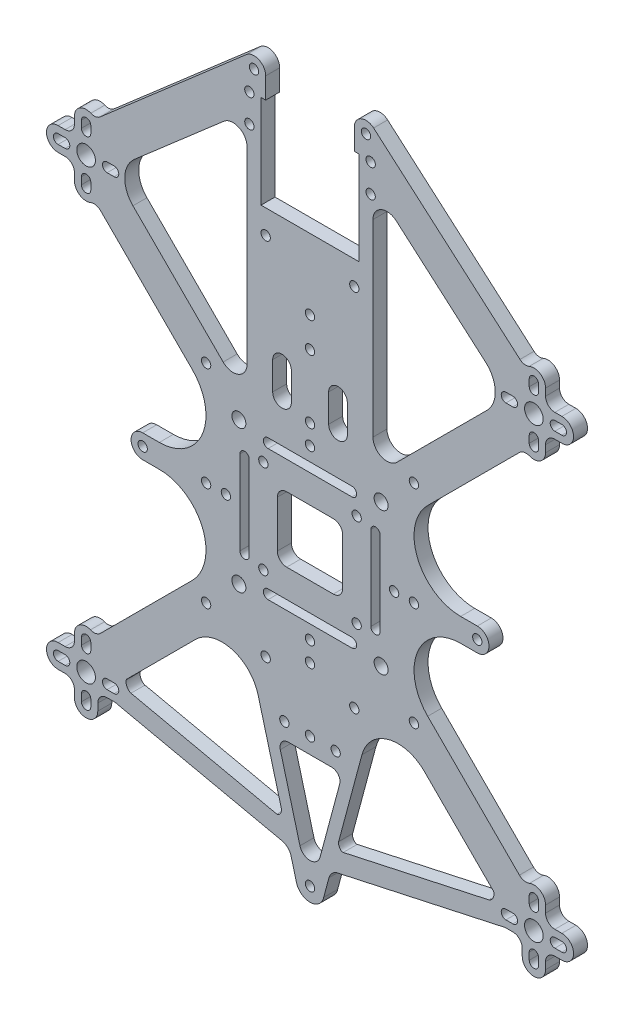
from build123d import *

# Parameters (mm, degrees)
MODEL_R         = 1
MODEL_R_2       = 2
MODEL_R_3       = 1.5
EXTRUDE_1_DEPTH = 3


with BuildPart() as part:
    # Model → 凸台-拉伸1 (new body)
    with BuildSketch(Plane.XY):
        with BuildLine():
            Line((38.972168987, 86.626017935), (42.537402622, 86.626017935))
            ThreePointArc((42.537402622, 86.626017935), (51.776388707, 92.799644178), (49.607765401, 103.69779071))
            Line((49.607765401, 103.69779071), (29.942441108, 123.35919406))
            ThreePointArc((29.942441108, 123.35919406), (28.926588779, 123.904793752), (27.778364563, 123.798887513))
            ThreePointArc((27.778364563, 123.798887513), (25.443319321, 124.043555525), (24.340859577, 126.116447523))
            Line((24.340859577, 126.116447523), (24.340859577, 127.616447523))
            ThreePointArc((24.340859577, 127.616447523), (23.755073139, 129.030661085), (22.340859577, 129.616447523))
            Line((22.340859577, 129.616447523), (20.840859577, 129.616447523))
            ThreePointArc((20.840859577, 129.616447523), (18.340859577, 132.116447523), (20.840859577, 134.616447523))
            Line((20.840859577, 134.616447523), (22.340859577, 134.616447523))
            ThreePointArc((22.340859577, 134.616447523), (23.755073139, 135.20223396), (24.340859577, 136.616447523))
            Line((24.340859577, 136.616447523), (24.340859577, 138.116447523))
            ThreePointArc((24.340859577, 138.116447523), (25.472512866, 140.208725535), (27.8429614, 140.406816911))
            ThreePointArc((27.8429614, 140.406816911), (28.877503873, 140.271078773), (29.824404932, 140.709349642))
            Line((29.824404932, 140.709349642), (61.200947719, 167.97768131))
            ThreePointArc((61.200947719, 167.97768131), (63.877734776, 168.365540898), (65.340859577, 166.090702481))
            Line((65.340859577, 166.090702481), (65.340859577, 161.590702481))
            Line((65.340859577, 161.590702481), (64.340859577, 161.590702481))
            Line((64.340859577, 161.590702481), (64.340859577, 141.590702481))
            Line((64.340859577, 141.590702481), (74.840859577, 141.590702481))
            Line((74.840859577, 141.590702481), (85.340859577, 141.590702481))
            Line((85.340859577, 141.590702481), (85.340859577, 161.590702481))
            Line((85.340859577, 161.590702481), (84.340859577, 161.590702481))
            Line((84.340859577, 161.590702481), (84.340859577, 166.090702481))
            ThreePointArc((84.340859577, 166.090702481), (85.803984377, 168.365540898), (88.480771434, 167.97768131))
            Line((88.480771434, 167.97768131), (119.857314221, 140.709349642))
            ThreePointArc((119.857314221, 140.709349642), (120.80421528, 140.271078773), (121.838757753, 140.406816911))
            ThreePointArc((121.838757753, 140.406816911), (124.209206287, 140.208725535), (125.340859577, 138.116447523))
            Line((125.340859577, 138.116447523), (125.340859577, 136.616447523))
            ThreePointArc((125.340859577, 136.616447523), (125.926646014, 135.20223396), (127.340859577, 134.616447523))
            Line((127.340859577, 134.616447523), (128.840859577, 134.616447523))
            ThreePointArc((128.840859577, 134.616447523), (131.340859577, 132.116447523), (128.840859577, 129.616447523))
            Line((128.840859577, 129.616447523), (127.340859576, 129.616447523))
            ThreePointArc((127.340859576, 129.616447523), (125.926646014, 129.030661085), (125.340859577, 127.616447523))
            Line((125.340859577, 127.616447523), (125.340859577, 126.116447523))
            ThreePointArc((125.340859577, 126.116447523), (124.238399832, 124.043555525), (121.90335459, 123.798887513))
            ThreePointArc((121.90335459, 123.798887513), (120.755130374, 123.904793752), (119.739278045, 123.35919406))
            Line((119.739278045, 123.35919406), (100.073953752, 103.69779071))
            ThreePointArc((100.073953752, 103.69779071), (97.905330446, 92.799644178), (107.144316531, 86.626017935))
            Line((107.144316531, 86.626017935), (110.709550166, 86.626017935))
            ThreePointArc((110.709550166, 86.626017935), (113.209550166, 84.126017935), (110.709550166, 81.626017935))
            Line((110.709550166, 81.626017935), (107.144316531, 81.626017935))
            ThreePointArc((107.144316531, 81.626017935), (97.905330446, 75.452391692), (100.073953752, 64.554245161))
            Line((100.073953752, 64.554245161), (119.739278045, 44.892841811))
            ThreePointArc((119.739278045, 44.892841811), (120.755130374, 44.347242119), (121.90335459, 44.453148358))
            ThreePointArc((121.90335459, 44.453148358), (124.238399832, 44.208480346), (125.340859577, 42.135588348))
            Line((125.340859577, 42.135588348), (125.340859577, 40.635588348))
            ThreePointArc((125.340859577, 40.635588348), (125.926646014, 39.221374786), (127.340859576, 38.635588348))
            Line((127.340859576, 38.635588348), (128.840859577, 38.635588348))
            ThreePointArc((128.840859577, 38.635588348), (131.340859577, 36.135588348), (128.840859577, 33.635588348))
            Line((128.840859577, 33.635588348), (127.340859577, 33.635588348))
            ThreePointArc((127.340859577, 33.635588348), (125.926646014, 33.04980191), (125.340859577, 31.635588348))
            Line((125.340859577, 31.635588348), (125.340859577, 30.135588348))
            ThreePointArc((125.340859577, 30.135588348), (122.840859577, 27.635588348), (120.340859577, 30.135588348))
            Line((120.340859577, 30.135588348), (120.340859577, 31.635588348))
            ThreePointArc((120.340859577, 31.635588348), (119.755073139, 33.04980191), (118.340859577, 33.635588348))
            Line((118.340859577, 33.635588348), (116.840859577, 33.635588348))
            add(Edge.make_bspline(
                [(116.840859577, 33.635588348), (116.34255425, 33.635588348), (115.860707104, 33.454297587), (115.373829919, 33.348190073)],
                knots=[0, 0, 0, 0, 1.494915979, 1.494915979, 1.494915979, 1.494915979], degree=3))
            Line((115.373829919, 33.348190073), (80.723908774, 25.79676417))
            add(Edge.make_bspline(
                [(80.723908774, 25.79676417), (79.89214197, 25.615493184), (79.128532898, 24.823201601), (78.908050638, 24.000959082)],
                knots=[0, 0, 0, 0, 2.553870922, 2.553870922, 2.553870922, 2.553870922], degree=3))
            Line((78.908050638, 24.000959082), (77.772158343, 19.764886112))
            ThreePointArc((77.772158343, 19.764886112), (74.877521116, 17.403457641), (71.926037039, 19.693438174))
            Line((71.926037039, 19.693438174), (70.773668515, 24.000959082))
            add(Edge.make_bspline(
                [(68.957810379, 25.79676417), (69.789577183, 25.615493184), (70.553186255, 24.823201601), (70.773668515, 24.000959082)],
                knots=[0, 0, 0, 0, 2.553870922, 2.553870922, 2.553870922, 2.553870922], degree=3))
            Line((68.957810379, 25.79676417), (34.307889234, 33.348190073))
            add(Edge.make_bspline(
                [(32.840859577, 33.635588348), (33.339164903, 33.635588348), (33.821012049, 33.454297587), (34.307889234, 33.348190073)],
                knots=[0, 0, 0, 0, 1.494915979, 1.494915979, 1.494915979, 1.494915979], degree=3))
            Line((32.840859577, 33.635588348), (31.340859577, 33.635588348))
            ThreePointArc((31.340859577, 33.635588348), (29.926646014, 33.04980191), (29.340859577, 31.635588348))
            Line((29.340859577, 31.635588348), (29.340859577, 30.135588348))
            ThreePointArc((29.340859577, 30.135588348), (26.840859577, 27.635588348), (24.340859577, 30.135588348))
            Line((24.340859577, 30.135588348), (24.340859577, 31.635588348))
            ThreePointArc((24.340859577, 31.635588348), (23.755073139, 33.04980191), (22.340859577, 33.635588348))
            Line((22.340859577, 33.635588348), (20.840859577, 33.635588348))
            ThreePointArc((20.840859577, 33.635588348), (18.340859577, 36.135588348), (20.840859577, 38.635588348))
            Line((20.840859577, 38.635588348), (22.340859577, 38.635588348))
            ThreePointArc((22.340859577, 38.635588348), (23.755073139, 39.221374786), (24.340859577, 40.635588348))
            Line((24.340859577, 40.635588348), (24.340859577, 42.135588348))
            ThreePointArc((24.340859577, 42.135588348), (25.443319321, 44.208480346), (27.778364563, 44.453148358))
            ThreePointArc((27.778364563, 44.453148358), (28.926588779, 44.347242119), (29.942441108, 44.892841811))
            Line((29.942441108, 44.892841811), (49.607765401, 64.554245161))
            ThreePointArc((49.607765401, 64.554245161), (51.776388707, 75.452391692), (42.537402622, 81.626017935))
            Line((42.537402622, 81.626017935), (38.972168987, 81.626017935))
            ThreePointArc((38.972168987, 81.626017935), (36.472168987, 84.126017935), (38.972168987, 86.626017935))
        make_face()
        with Locations((97.114723184, 106.399881543)):
            Circle(MODEL_R, mode=Mode.SUBTRACT)
        with Locations((52.566995969, 106.399881543)):
            Circle(MODEL_R, mode=Mode.SUBTRACT)
        with Locations((52.566995969, 61.852154328)):
            Circle(MODEL_R, mode=Mode.SUBTRACT)
        with Locations((97.114723184, 61.852154328)):
            Circle(MODEL_R, mode=Mode.SUBTRACT)
        with Locations((97.114723184, 84.126017935)):
            Circle(MODEL_R, mode=Mode.SUBTRACT)
        with Locations((74.840859577, 106.399881543)):
            Circle(MODEL_R, mode=Mode.SUBTRACT)
        with Locations((52.566995969, 84.126017935)):
            Circle(MODEL_R, mode=Mode.SUBTRACT)
        with Locations((74.840859577, 61.852154328)):
            Circle(MODEL_R, mode=Mode.SUBTRACT)
        with Locations((64.840859577, 94.126017935)):
            Circle(MODEL_R, mode=Mode.SUBTRACT)
        with Locations((84.840859577, 94.126017935)):
            Circle(MODEL_R, mode=Mode.SUBTRACT)
        with Locations((64.840859577, 74.126017935)):
            Circle(MODEL_R, mode=Mode.SUBTRACT)
        with Locations((84.840859577, 74.126017935)):
            Circle(MODEL_R, mode=Mode.SUBTRACT)
        with Locations((26.840859577, 132.116447523)):
            Circle(MODEL_R_2, mode=Mode.SUBTRACT)
        with Locations((74.840859577, 102.157240856)):
            Circle(MODEL_R, mode=Mode.SUBTRACT)
        with Locations((92.872082497, 84.126017935)):
            Circle(MODEL_R, mode=Mode.SUBTRACT)
        with Locations((74.840859577, 66.094795015)):
            Circle(MODEL_R, mode=Mode.SUBTRACT)
        with Locations((56.809636656, 84.126017935)):
            Circle(MODEL_R, mode=Mode.SUBTRACT)
        with Locations((110.709550166, 84.126017935)):
            Circle(MODEL_R, mode=Mode.SUBTRACT)
        with Locations((38.972168987, 84.126017935)):
            Circle(MODEL_R, mode=Mode.SUBTRACT)
        with Locations((74.840859577, 120.0230609)):
            Circle(MODEL_R, mode=Mode.SUBTRACT)
        with Locations((74.840859577, 48.22897497)):
            Circle(MODEL_R, mode=Mode.SUBTRACT)
        with Locations((26.840859577, 36.135588348)):
            Circle(MODEL_R_2, mode=Mode.SUBTRACT)
        with Locations((122.840859577, 36.135588348)):
            Circle(MODEL_R_2, mode=Mode.SUBTRACT)
        with Locations((62.840859577, 166.090702481)):
            Circle(MODEL_R, mode=Mode.SUBTRACT)
        with Locations((86.840859577, 166.090702481)):
            Circle(MODEL_R, mode=Mode.SUBTRACT)
        with Locations((74.840859577, 20.403233621)):
            Circle(MODEL_R, mode=Mode.SUBTRACT)
        with Locations((122.840859577, 132.116447523)):
            Circle(MODEL_R_2, mode=Mode.SUBTRACT)
        with Locations((65.340859577, 136.477543572)):
            Circle(MODEL_R, mode=Mode.SUBTRACT)
        with Locations((84.340859577, 136.477543572)):
            Circle(MODEL_R, mode=Mode.SUBTRACT)
        with Locations((90.090859577, 99.376017935)):
            Circle(MODEL_R_3, mode=Mode.SUBTRACT)
        with Locations((59.590859577, 99.376017935)):
            Circle(MODEL_R_3, mode=Mode.SUBTRACT)
        with Locations((90.090859577, 68.876017935)):
            Circle(MODEL_R_3, mode=Mode.SUBTRACT)
        with Locations((59.590859577, 68.876017935)):
            Circle(MODEL_R_3, mode=Mode.SUBTRACT)
        with Locations((87.840859577, 161.3753096)):
            Circle(MODEL_R, mode=Mode.SUBTRACT)
        with Locations((87.840859577, 155.3753096)):
            Circle(MODEL_R, mode=Mode.SUBTRACT)
        with Locations((61.840859577, 161.3753096)):
            Circle(MODEL_R, mode=Mode.SUBTRACT)
        with Locations((61.840859577, 155.3753096)):
            Circle(MODEL_R, mode=Mode.SUBTRACT)
        with Locations((74.840859577, 126.477543572)):
            Circle(MODEL_R, mode=Mode.SUBTRACT)
        with Locations((65.340859577, 58.22897497)):
            Circle(MODEL_R, mode=Mode.SUBTRACT)
        with Locations((84.340859577, 58.22897497)):
            Circle(MODEL_R, mode=Mode.SUBTRACT)
        with Locations((80.340859577, 48.22897497)):
            Circle(MODEL_R, mode=Mode.SUBTRACT)
        with Locations((69.340859577, 48.22897497)):
            Circle(MODEL_R, mode=Mode.SUBTRACT)
        with BuildLine():
            Line((37.185851185, 136.507989838), (56.372965348, 153.182885995))
            ThreePointArc((56.372965348, 153.182885995), (59.585109815, 153.6483175), (61.340859577, 150.9185114))
            Line((61.340859577, 150.9185114), (61.340859577, 110.521236193))
            ThreePointArc((61.340859577, 110.521236193), (59.489048041, 107.749654831), (56.219750743, 108.399704361))
            Line((56.219750743, 108.399704361), (36.879421975, 127.736176984))
            ThreePointArc((36.879421975, 127.736176984), (35.125297322, 132.188713248), (37.185851185, 136.507989838))
        make_face(mode=Mode.SUBTRACT)
        with BuildLine():
            Line((27.840859577, 136.616447523), (27.840859577, 138.116447523))
            ThreePointArc((27.840859577, 138.116447523), (26.840859577, 139.116447523), (25.840859577, 138.116447523))
            Line((25.840859577, 138.116447523), (25.840859577, 136.616447523))
            ThreePointArc((25.840859577, 136.616447523), (26.840859577, 135.616447523), (27.840859577, 136.616447523))
        make_face(mode=Mode.SUBTRACT)
        with BuildLine():
            Line((27.840859577, 127.616447523), (27.840859577, 126.116447523))
            ThreePointArc((27.840859577, 126.116447523), (26.840859577, 125.116447523), (25.840859577, 126.116447523))
            Line((25.840859577, 126.116447523), (25.840859577, 127.616447523))
            ThreePointArc((25.840859577, 127.616447523), (26.840859577, 128.616447523), (27.840859577, 127.616447523))
        make_face(mode=Mode.SUBTRACT)
        with BuildLine():
            Line((22.340859577, 133.116447523), (20.840859577, 133.116447523))
            ThreePointArc((20.840859577, 133.116447523), (19.840859577, 132.116447523), (20.840859577, 131.116447523))
            Line((20.840859577, 131.116447523), (22.340859577, 131.116447523))
            ThreePointArc((22.340859577, 131.116447523), (23.340859577, 132.116447523), (22.340859577, 133.116447523))
        make_face(mode=Mode.SUBTRACT)
        with BuildLine():
            Line((31.340859577, 133.116447523), (32.840859577, 133.116447523))
            ThreePointArc((32.840859577, 133.116447523), (33.840859577, 132.116447523), (32.840859577, 131.116447523))
            Line((32.840859577, 131.116447523), (31.340859577, 131.116447523))
            ThreePointArc((31.340859577, 131.116447523), (30.340859577, 132.116447523), (31.340859577, 133.116447523))
        make_face(mode=Mode.SUBTRACT)
        with BuildLine():
            Line((27.840859577, 31.635588348), (27.840859577, 30.135588348))
            ThreePointArc((27.840859577, 30.135588348), (26.840859577, 29.135588348), (25.840859577, 30.135588348))
            Line((25.840859577, 30.135588348), (25.840859577, 31.635588348))
            ThreePointArc((25.840859577, 31.635588348), (26.840859577, 32.635588348), (27.840859577, 31.635588348))
        make_face(mode=Mode.SUBTRACT)
        with BuildLine():
            Line((27.840859577, 40.635588348), (27.840859577, 42.135588348))
            ThreePointArc((27.840859577, 42.135588348), (26.840859577, 43.135588348), (25.840859577, 42.135588348))
            Line((25.840859577, 42.135588348), (25.840859577, 40.635588348))
            ThreePointArc((25.840859577, 40.635588348), (26.840859577, 39.635588348), (27.840859577, 40.635588348))
        make_face(mode=Mode.SUBTRACT)
        with BuildLine():
            Line((22.340859577, 35.135588348), (20.840859577, 35.135588348))
            ThreePointArc((20.840859577, 35.135588348), (19.840859577, 36.135588348), (20.840859577, 37.135588348))
            Line((20.840859577, 37.135588348), (22.340859577, 37.135588348))
            ThreePointArc((22.340859577, 37.135588348), (23.340859577, 36.135588348), (22.340859577, 35.135588348))
        make_face(mode=Mode.SUBTRACT)
        with BuildLine():
            Line((31.340859577, 35.135588348), (32.840859577, 35.135588348))
            ThreePointArc((32.840859577, 35.135588348), (33.840859577, 36.135588348), (32.840859577, 37.135588348))
            Line((32.840859577, 37.135588348), (31.340859577, 37.135588348))
            ThreePointArc((31.340859577, 37.135588348), (30.340859577, 36.135588348), (31.340859577, 35.135588348))
        make_face(mode=Mode.SUBTRACT)
        with BuildLine():
            Line((121.840859577, 31.635588348), (121.840859577, 30.135588348))
            ThreePointArc((121.840859577, 30.135588348), (122.840859577, 29.135588348), (123.840859577, 30.135588348))
            Line((123.840859577, 30.135588348), (123.840859577, 31.635588348))
            ThreePointArc((123.840859577, 31.635588348), (122.840859577, 32.635588348), (121.840859577, 31.635588348))
        make_face(mode=Mode.SUBTRACT)
        with BuildLine():
            Line((121.840859577, 40.635588348), (121.840859577, 42.135588348))
            ThreePointArc((121.840859577, 42.135588348), (122.840859577, 43.135588348), (123.840859577, 42.135588348))
            Line((123.840859577, 42.135588348), (123.840859577, 40.635588348))
            ThreePointArc((123.840859577, 40.635588348), (122.840859577, 39.635588348), (121.840859577, 40.635588348))
        make_face(mode=Mode.SUBTRACT)
        with BuildLine():
            Line((127.340859577, 35.135588348), (128.840859577, 35.135588348))
            ThreePointArc((128.840859577, 35.135588348), (129.840859577, 36.135588348), (128.840859577, 37.135588348))
            Line((128.840859577, 37.135588348), (127.340859577, 37.135588348))
            ThreePointArc((127.340859577, 37.135588348), (126.340859577, 36.135588348), (127.340859577, 35.135588348))
        make_face(mode=Mode.SUBTRACT)
        with BuildLine():
            Line((118.340859577, 35.135588348), (116.840859577, 35.135588348))
            ThreePointArc((116.840859577, 35.135588348), (115.840859577, 36.135588348), (116.840859577, 37.135588348))
            Line((116.840859577, 37.135588348), (118.340859577, 37.135588348))
            ThreePointArc((118.340859577, 37.135588348), (119.340859577, 36.135588348), (118.340859577, 35.135588348))
        make_face(mode=Mode.SUBTRACT)
        with BuildLine():
            Line((114.082643343, 39.235768001), (99.361708586, 53.953767646))
            ThreePointArc((99.361708586, 53.953767646), (91.634480786, 56.023652808), (85.978011752, 50.366901787))
            Line((85.978011752, 50.366901787), (80.980032505, 31.727982515))
            add(Edge.make_bspline(
                [(80.980032505, 31.727982515), (80.824438553, 31.147727381), (81.370122086, 30.085632094), (81.957098492, 30.213554718)],
                knots=[0, 0, 0, 0, 1.802262327, 1.802262327, 1.802262327, 1.802262327], degree=3))
            Line((81.957098492, 30.213554718), (113.223210075, 37.02753054))
            add(Edge.make_bspline(
                [(114.082643343, 39.235768001), (114.641215823, 38.677306892), (113.994957398, 37.195721189), (113.223210075, 37.02753054)],
                knots=[0, 0, 0, 0, 2.369586088, 2.369586088, 2.369586088, 2.369586088], degree=3))
        make_face(mode=Mode.SUBTRACT)
        with BuildLine():
            Line((81.211357059, 42.56278264), (76.99262694, 26.818267492))
            ThreePointArc((76.99262694, 26.818267492), (74.840859577, 25.167158322), (72.689092213, 26.818267492))
            Line((72.689092213, 26.818267492), (68.470362094, 42.56278264))
            ThreePointArc((68.470362094, 42.56278264), (68.777910217, 44.108931463), (70.191775985, 44.8061729))
            Line((70.191775985, 44.8061729), (79.489943168, 44.8061729))
            ThreePointArc((79.489943168, 44.8061729), (80.903808936, 44.108931463), (81.211357059, 42.56278264))
        make_face(mode=Mode.SUBTRACT)
        with BuildLine():
            Line((121.840859577, 136.616447523), (121.840859577, 138.116447523))
            ThreePointArc((121.840859577, 138.116447523), (122.840859577, 139.116447523), (123.840859577, 138.116447523))
            Line((123.840859577, 138.116447523), (123.840859577, 136.616447523))
            ThreePointArc((123.840859577, 136.616447523), (122.840859577, 135.616447523), (121.840859577, 136.616447523))
        make_face(mode=Mode.SUBTRACT)
        with BuildLine():
            Line((121.840859577, 127.616447523), (121.840859577, 126.116447523))
            ThreePointArc((121.840859577, 126.116447523), (122.840859577, 125.116447523), (123.840859577, 126.116447523))
            Line((123.840859577, 126.116447523), (123.840859577, 127.616447523))
            ThreePointArc((123.840859577, 127.616447523), (122.840859577, 128.616447523), (121.840859577, 127.616447523))
        make_face(mode=Mode.SUBTRACT)
        with BuildLine():
            Line((127.340859577, 133.116447523), (128.840859577, 133.116447523))
            ThreePointArc((128.840859577, 133.116447523), (129.840859577, 132.116447523), (128.840859577, 131.116447523))
            Line((128.840859577, 131.116447523), (127.340859577, 131.116447523))
            ThreePointArc((127.340859577, 131.116447523), (126.340859577, 132.116447523), (127.340859577, 133.116447523))
        make_face(mode=Mode.SUBTRACT)
        with BuildLine():
            Line((118.340859577, 133.116447523), (116.840859577, 133.116447523))
            ThreePointArc((116.840859577, 133.116447523), (115.840859577, 132.116447523), (116.840859577, 131.116447523))
            Line((116.840859577, 131.116447523), (118.340859577, 131.116447523))
            ThreePointArc((118.340859577, 131.116447523), (119.340859577, 132.116447523), (118.340859577, 133.116447523))
        make_face(mode=Mode.SUBTRACT)
        with BuildLine():
            Line((112.495867968, 136.507989838), (93.308753805, 153.182885995))
            ThreePointArc((93.308753805, 153.182885995), (90.096609338, 153.6483175), (88.340859577, 150.9185114))
            Line((88.340859577, 150.9185114), (88.340859577, 110.521236193))
            ThreePointArc((88.340859577, 110.521236193), (90.192671112, 107.749654831), (93.46196841, 108.399704361))
            Line((93.46196841, 108.399704361), (112.802297178, 127.736176984))
            ThreePointArc((112.802297178, 127.736176984), (114.556421831, 132.188713248), (112.495867968, 136.507989838))
        make_face(mode=Mode.SUBTRACT)
        with BuildLine():
            Line((61.809636656, 93.126017935), (61.809636656, 75.126017935))
            ThreePointArc((61.809636656, 75.126017935), (60.809636656, 74.126017935), (59.809636656, 75.126017935))
            Line((59.809636656, 75.126017935), (59.809636656, 93.126017935))
            ThreePointArc((59.809636656, 93.126017935), (60.102529875, 93.833124717), (60.809636656, 94.126017935))
            ThreePointArc((60.809636656, 94.126017935), (61.516743437, 93.833124717), (61.809636656, 93.126017935))
        make_face(mode=Mode.SUBTRACT)
        with BuildLine():
            Line((69.840859577, 91.126017935), (79.840859577, 91.126017935))
            ThreePointArc((79.840859577, 91.126017935), (81.255073139, 90.540231498), (81.840859577, 89.126017935))
            Line((81.840859577, 89.126017935), (81.840859577, 79.126017935))
            ThreePointArc((81.840859577, 79.126017935), (81.255073139, 77.711804373), (79.840859577, 77.126017935))
            Line((79.840859577, 77.126017935), (69.840859577, 77.126017935))
            ThreePointArc((69.840859577, 77.126017935), (68.426646014, 77.711804373), (67.840859577, 79.126017935))
            Line((67.840859577, 79.126017935), (67.840859577, 89.126017935))
            ThreePointArc((67.840859577, 89.126017935), (68.426646014, 90.540231498), (69.840859577, 91.126017935))
        make_face(mode=Mode.SUBTRACT)
        with BuildLine():
            Line((87.872082497, 93.126017935), (87.872082497, 75.126017935))
            ThreePointArc((87.872082497, 75.126017935), (88.872082497, 74.126017935), (89.872082497, 75.126017935))
            Line((89.872082497, 75.126017935), (89.872082497, 93.126017935))
            ThreePointArc((89.872082497, 93.126017935), (89.579189278, 93.833124717), (88.872082497, 94.126017935))
            ThreePointArc((88.872082497, 94.126017935), (88.164975716, 93.833124717), (87.872082497, 93.126017935))
        make_face(mode=Mode.SUBTRACT)
        with BuildLine():
            Line((65.840859577, 71.094795015), (83.840859577, 71.094795015))
            ThreePointArc((83.840859577, 71.094795015), (84.840859577, 70.094795015), (83.840859577, 69.094795015))
            Line((83.840859577, 69.094795015), (65.840859577, 69.094795015))
            ThreePointArc((65.840859577, 69.094795015), (65.133752795, 69.387688234), (64.840859577, 70.094795015))
            ThreePointArc((64.840859577, 70.094795015), (65.133752795, 70.801901796), (65.840859577, 71.094795015))
        make_face(mode=Mode.SUBTRACT)
        with BuildLine():
            Line((65.840859577, 97.157240856), (83.840859577, 97.157240856))
            ThreePointArc((83.840859577, 97.157240856), (84.840859577, 98.157240856), (83.840859577, 99.157240856))
            Line((83.840859577, 99.157240856), (65.840859577, 99.157240856))
            ThreePointArc((65.840859577, 99.157240856), (65.133752795, 98.864347637), (64.840859577, 98.157240856))
            ThreePointArc((64.840859577, 98.157240856), (65.133752795, 97.450134074), (65.840859577, 97.157240856))
        make_face(mode=Mode.SUBTRACT)
        with BuildLine():
            Line((70.840859577, 114.157240856), (70.840859577, 108.157240856))
            ThreePointArc((70.840859577, 108.157240856), (68.840859577, 106.157240856), (66.840859577, 108.157240856))
            Line((66.840859577, 108.157240856), (66.840859577, 114.157240856))
            ThreePointArc((66.840859577, 114.157240856), (67.426646014, 115.571454418), (68.840859577, 116.157240856))
            ThreePointArc((68.840859577, 116.157240856), (70.255073139, 115.571454418), (70.840859577, 114.157240856))
        make_face(mode=Mode.SUBTRACT)
        with BuildLine():
            Line((78.840859577, 114.157240856), (78.840859577, 108.157240856))
            ThreePointArc((78.840859577, 108.157240856), (80.840859577, 106.157240856), (82.840859577, 108.157240856))
            Line((82.840859577, 108.157240856), (82.840859577, 114.157240856))
            ThreePointArc((82.840859577, 114.157240856), (82.255073139, 115.571454418), (80.840859577, 116.157240856))
            ThreePointArc((80.840859577, 116.157240856), (79.426646014, 115.571454418), (78.840859577, 114.157240856))
        make_face(mode=Mode.SUBTRACT)
        with BuildLine():
            Line((35.59907581, 39.235768001), (50.320010567, 53.953767646))
            ThreePointArc((50.320010567, 53.953767646), (58.047238367, 56.023652808), (63.703707401, 50.366901787))
            Line((63.703707401, 50.366901787), (68.701686648, 31.727982515))
            add(Edge.make_bspline(
                [(68.701686648, 31.727982515), (68.8572806, 31.147727381), (68.311597067, 30.085632094), (67.724620661, 30.213554718)],
                knots=[0, 0, 0, 0, 1.802262327, 1.802262327, 1.802262327, 1.802262327], degree=3))
            Line((67.724620661, 30.213554718), (36.458509078, 37.02753054))
            add(Edge.make_bspline(
                [(35.59907581, 39.235768001), (35.04050333, 38.677306892), (35.686761755, 37.195721189), (36.458509078, 37.02753054)],
                knots=[0, 0, 0, 0, 2.369586088, 2.369586088, 2.369586088, 2.369586088], degree=3))
        make_face(mode=Mode.SUBTRACT)
    extrude(amount=EXTRUDE_1_DEPTH)


solid = part.part
